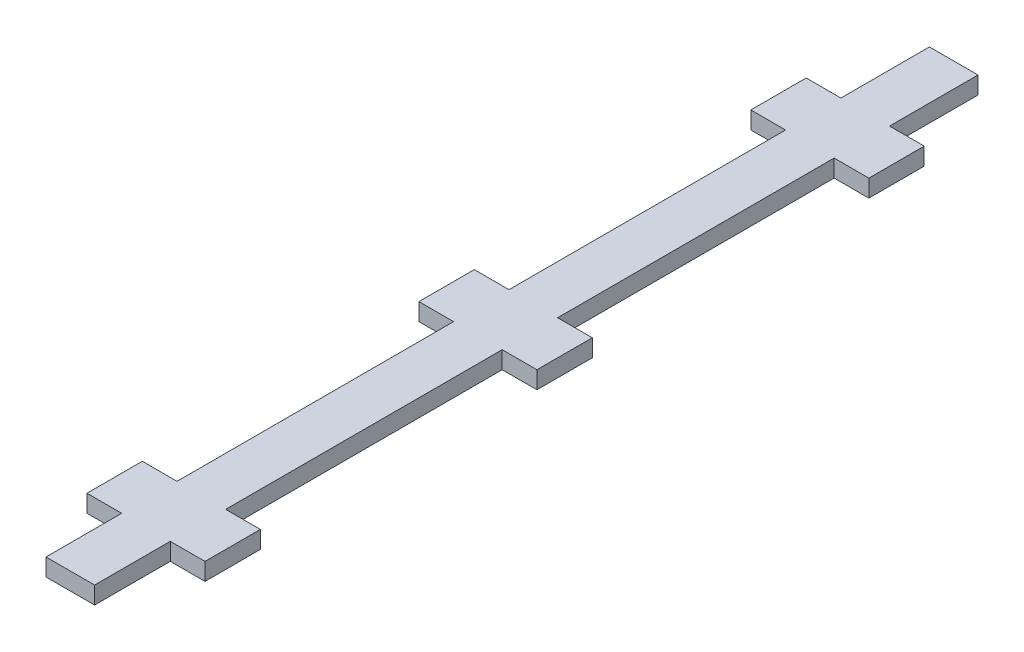
from build123d import *

# Parameters (mm, degrees)
BOSS_EXTRUDE1_DEPTH = 3.175


with BuildPart() as part:
    # Sketch1 → Boss-Extrude1 (new body)
    with BuildSketch(Plane(origin=(0, 0, 0), x_dir=(1, 0, 0), z_dir=(0, 1, 0))):
        Polygon((4.445, 0), (-4.445, 0), (-4.445, 13.843), (-10.795, 13.843), (-10.795, 23.974869246), (-4.445, 23.974869246), (-4.445, 74.564887446), (-10.795, 74.564887446), (-10.795, 84.696756692), (-4.445, 84.696756692), (-4.445, 135.286774892), (-10.795, 135.286774892), (-10.795, 145.418644138), (-4.445, 145.418644138), (-4.445, 161.605283342), (4.445, 161.605283342), (4.445, 145.418644138), (10.795, 145.418644138), (10.795, 135.286774892), (4.445, 135.286774892), (4.445, 84.696756692), (10.795, 84.696756692), (10.795, 74.564887446), (4.445, 74.564887446), (4.445, 23.974869246), (10.795, 23.974869246), (10.795, 13.843), (4.445, 13.843), align=None)
    extrude(amount=BOSS_EXTRUDE1_DEPTH)


solid = part.part
